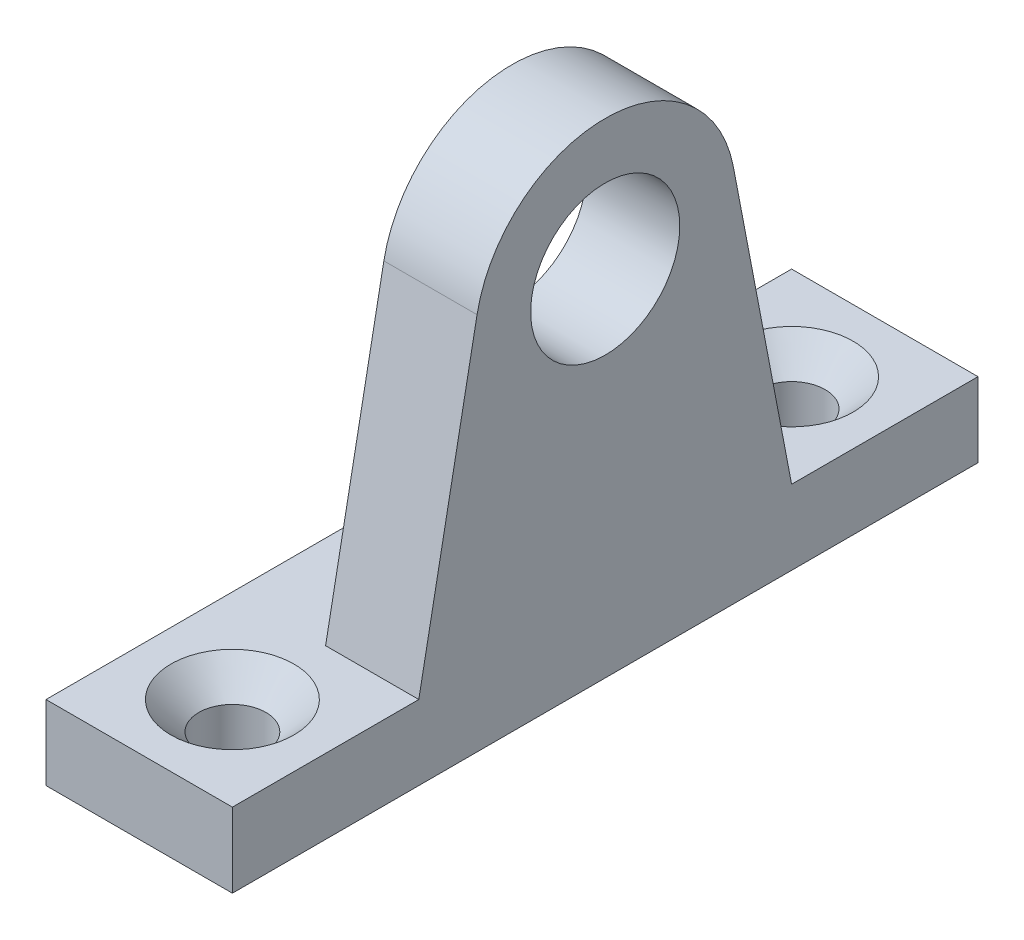
from build123d import *

# Parameters (mm, degrees)
SKETCH_1_R                = 4
EXTRUDE_1_DEPTH           = 5
SKETCH_2_W                = 5
SKETCH_2_H                = 40
EXTRUDE_2_DEPTH           = 4
HOLE_WIZARD_1_D           = 3.6
HOLE_WIZARD_1_CSINK_D     = 6.6
HOLE_WIZARD_1_CSINK_ANGLE = 90


with BuildPart() as part:
    # 草图1 → 凸台-拉伸1 (new body)
    with BuildSketch(Plane(origin=(0, 0, 0), x_dir=(0, 0, -1), z_dir=(1, 0, 0))):
        with BuildLine():
            Line((-6.875049265, 20.31669951), (-10, 4))
            Line((-10, 4), (-20, 4))
            Line((-20, 4), (-20, 0))
            Line((-20, 0), (20, 0))
            Line((20, 0), (20, 4))
            Line((20, 4), (10, 4))
            Line((10, 4), (6.875049265, 20.31669951))
            ThreePointArc((6.875049265, 20.31669951), (0, 26), (-6.875049265, 20.31669951))
        make_face()
        with Locations((0, 19)):
            Circle(SKETCH_1_R, mode=Mode.SUBTRACT)
    extrude(amount=EXTRUDE_1_DEPTH)

    # 草图2 → 凸台-拉伸2 (add)
    with BuildSketch(Plane(origin=(0, 4, 0), x_dir=(1, 0, 0), z_dir=(0, 1, 0))):
        with Locations((-2.5, 0)):
            Rectangle(SKETCH_2_W, SKETCH_2_H)
    extrude(amount=-EXTRUDE_2_DEPTH)

    # 打孔尺寸(%根据十字)槽半沉头木螺钉的类型1 (through all)
    with Locations(Plane(origin=(0, 4, 0), x_dir=(1, 0, 0), z_dir=(0, 1, 0))):
        with Locations((0, 15), (0, -15)):
            CounterSinkHole(HOLE_WIZARD_1_D / 2, HOLE_WIZARD_1_CSINK_D / 2, counter_sink_angle=HOLE_WIZARD_1_CSINK_ANGLE)


solid = part.part
